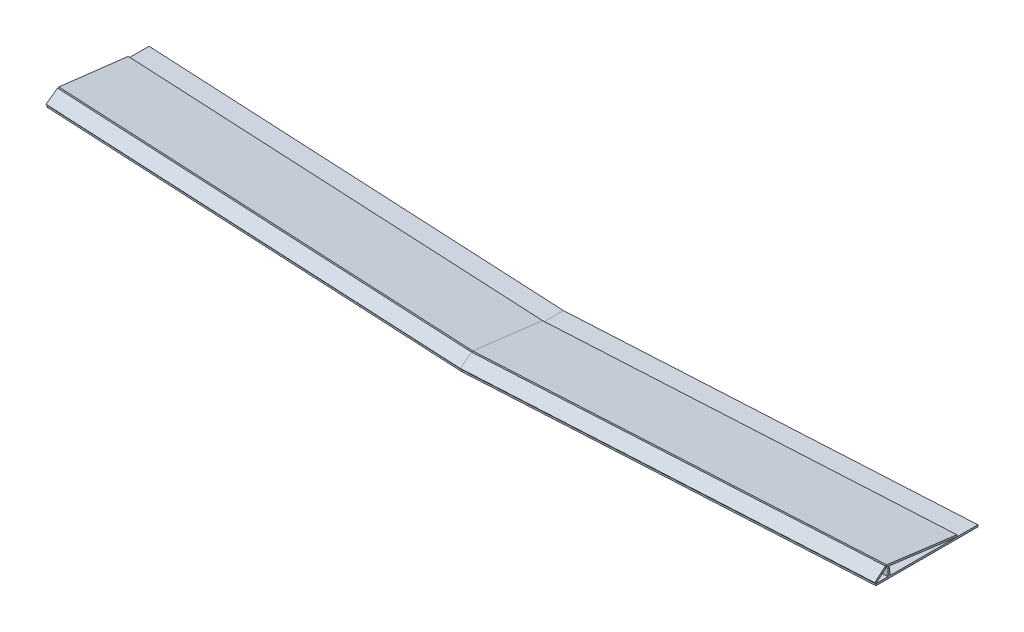
from build123d import *

# Parameters (mm, degrees)
BOSS_EXTRUDE4_DEPTH   = 749.3
BOSS_EXTRUDE4_2_DEPTH = 749.3
BOSS_EXTRUDE4_3_DEPTH = 749.3
SKETCH1_3_W           = 3.175
SKETCH1_3_H           = 12.7
BOSS_EXTRUDE6_DEPTH   = 749.3


with BuildPart() as part:
    # Sketch1 → Boss-Extrude4 (new body)
    with BuildSketch(Plane(origin=(0, 0, 0), x_dir=(0, 0, -1), z_dir=(0.9986295347545743, 0.05233595624293715, 0))):
        Polygon((0, 3.175), (0, 0), (184.15, 0), (184.15, 3.175), (146.05, 3.175), (25.4, 3.175), (25.4, 15.875), (22.225, 15.875), (22.225, 3.175), align=None)
    extrude(amount=BOSS_EXTRUDE4_DEPTH)


with BuildPart() as body_2:
    # Sketch1 → Boss-Extrude4 2 (new body)
    with BuildSketch(Plane(origin=(0, 0, 0), x_dir=(0, 0, -1), z_dir=(0.9986295347545743, 0.05233595624293715, 0))):
        Polygon((-1.95459219, 5.677038043), (0, 3.175), (20.016304348, 18.81173752), (18.061712158, 21.313775563), align=None)
    extrude(amount=BOSS_EXTRUDE4_2_DEPTH)


with BuildPart() as body_3:
    # Sketch1 → Boss-Extrude4 3 (new body)
    with BuildSketch(Plane(origin=(0, 0, 0), x_dir=(0, 0, -1), z_dir=(0.9986295347545743, 0.05233595624293715, 0))):
        Polygon((20.407222786, 21.962579911), (20.016304348, 18.81173752), (146.05, 3.175), (146.440918438, 6.325842391), align=None)
    extrude(amount=BOSS_EXTRUDE4_3_DEPTH)


with BuildPart() as body_4:
    # Sketch1_3 → Boss-Extrude6 (new body)
    with BuildSketch(Plane(origin=(0, 0, 0), x_dir=(0, 0, -1), z_dir=(0.9986295347545743, 0.05233595624293715, 0))):
        with Locations((23.8125, 9.525)):
            Rectangle(SKETCH1_3_W, SKETCH1_3_H)
    extrude(amount=BOSS_EXTRUDE6_DEPTH)


with BuildPart() as body_5:
    # Mirror5: mirrored copy
    add(body_2.part.mirror(Plane(origin=(0, 0, 0), x_dir=(0, 0, 1), z_dir=(1, 0, 0))))


with BuildPart() as body_6:
    # Mirror5 2: mirrored copy
    add(part.part.mirror(Plane(origin=(0, 0, 0), x_dir=(0, 0, 1), z_dir=(1, 0, 0))))


with BuildPart() as body_7:
    # Mirror5 3: mirrored copy
    add(body_4.part.mirror(Plane(origin=(0, 0, 0), x_dir=(0, 0, 1), z_dir=(1, 0, 0))))


with BuildPart() as body_8:
    # Mirror5 4: mirrored copy
    add(body_3.part.mirror(Plane(origin=(0, 0, 0), x_dir=(0, 0, 1), z_dir=(1, 0, 0))))


solid = Compound([part.part, body_2.part, body_3.part, body_4.part, body_5.part, body_6.part, body_7.part, body_8.part])
